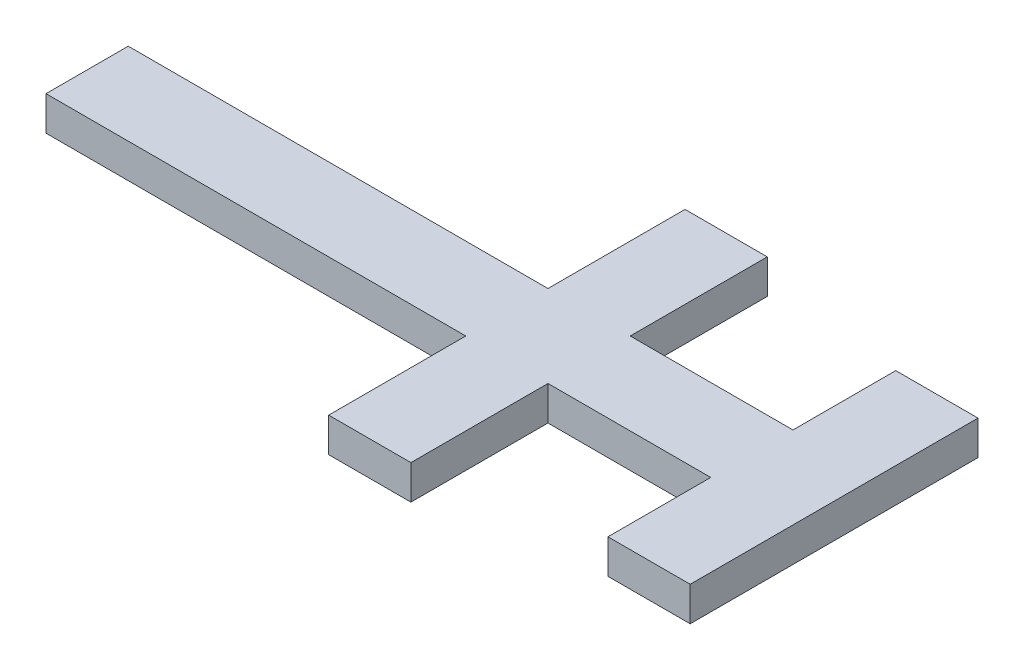
from build123d import *

# Parameters (mm, degrees)
SKETCH_3_W           = 10
SKETCH_3_H           = 40
SKETCH_3_W_2         = 25.75
SKETCH_3_H_2         = 10
SKETCH_3_W_3         = 36.25
SKETCH_3_W_4         = 25
EXTRUDE_1_DEPTH      = 1
EXTRUDE_2_DEPTH      = 4
EXTRUDE_2_DEPTH_BACK = 1
SKETCH_5_W           = 25
SKETCH_5_H           = 10
SKETCH_5_W_2         = 10
SKETCH_5_H_2         = 40
EXTRUDE_3_DEPTH      = 2


with BuildPart() as part:
    # 草图3 → 凸台-拉伸1 (new body)
    with BuildSketch(Plane(origin=(0, 0, 0), x_dir=(1, 0, 0), z_dir=(0, 1, 0))):
        with Locations((20, 0)):
            Rectangle(SKETCH_3_W, SKETCH_3_H)
        with Locations((2.125, 0)):
            Rectangle(SKETCH_3_W_2, SKETCH_3_H_2)
        Polygon((-10.75, -5), (-10.75, 5), (-10.75, 25), (-20.75, 25), (-20.75, 5), (-20.75, -5), (-20.75, -25), (-10.75, -25), align=None)
        with Locations((-38.875, 0)):
            Rectangle(SKETCH_3_W_3, SKETCH_3_H_2)
        with Locations((-69.5, 0)):
            Rectangle(SKETCH_3_W_4, SKETCH_3_H_2)
    extrude(amount=EXTRUDE_1_DEPTH)

    # 草图4 → 凸台-拉伸2 (add, two sides)
    with BuildSketch(Plane.XZ) as extrude_2_sk:
        Polygon((14, -21), (26, -21), (26, 21), (14, 21), (14, 6), (-9.75, 6), (-9.75, 26), (-21.75, 26), (-21.75, 6), (-83, 6), (-83, -6), (-21.75, -6), (-21.75, -26), (-9.75, -26), (-9.75, -6), (14, -6), align=None)
        Polygon((15, -20), (25, -20), (25, 20), (15, 20), (15, 5), (-10.75, 5), (-10.75, 25), (-20.75, 25), (-20.75, 5), (-82, 5), (-82, -5), (-20.75, -5), (-20.75, -25), (-10.75, -25), (-10.75, -5), (15, -5), align=None, mode=Mode.SUBTRACT)
    extrude(amount=EXTRUDE_2_DEPTH)
    extrude(extrude_2_sk.sketch, amount=-EXTRUDE_2_DEPTH_BACK)

    # 草图5 → 凸台-拉伸3 (add)
    with BuildSketch(Plane.XZ):
        Polygon((-20.75, 25), (-20.75, 5), (-17, 5), (-17, -5), (-20.75, -5), (-20.75, -25), (-10.75, -25), (-10.75, -5), (-15, -5), (-15, 5), (-10.75, 5), (-10.75, 25), align=None)
        with Locations((-69.5, 0)):
            Rectangle(SKETCH_5_W, SKETCH_5_H)
        with Locations((20, 0)):
            Rectangle(SKETCH_5_W_2, SKETCH_5_H_2)
    extrude(amount=EXTRUDE_3_DEPTH)


solid = part.part
